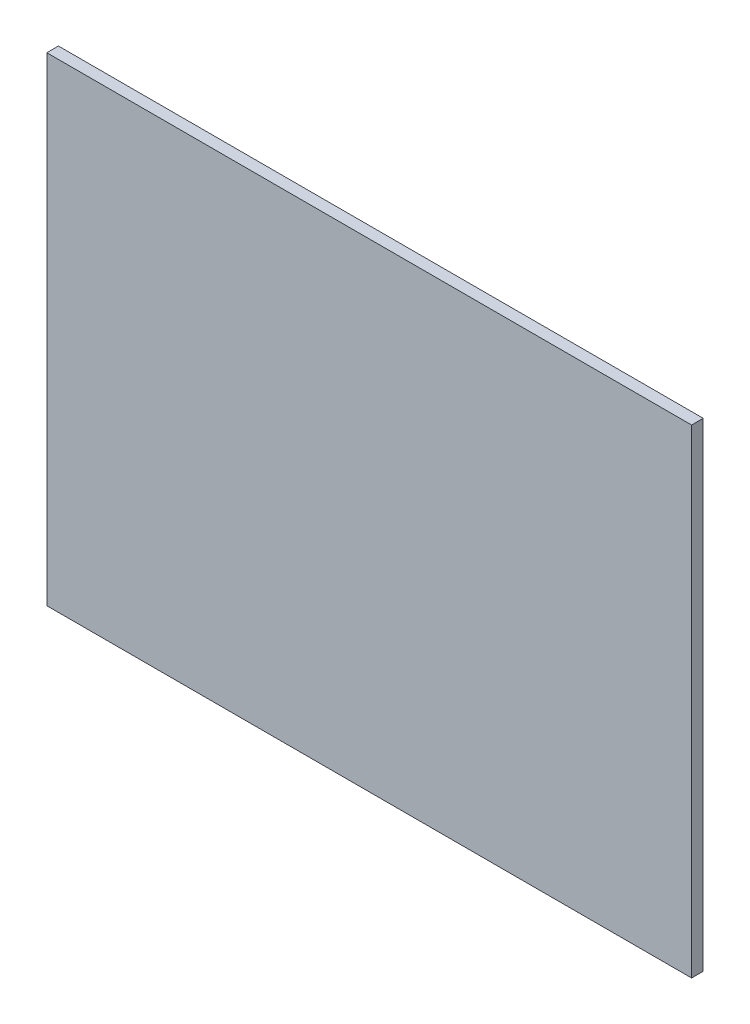
from build123d import *

# Parameters (mm, degrees)
SKETCH1_W           = 660.481708072
SKETCH1_H           = 490.53796101
BOSS_EXTRUDE1_DEPTH = 11.90625


with BuildPart() as part:
    # Sketch1 → Boss-Extrude1 (new body)
    with BuildSketch(Plane.XY):
        with Locations((0, 257.175230505)):
            Rectangle(SKETCH1_W, SKETCH1_H)
    extrude(amount=-BOSS_EXTRUDE1_DEPTH)


solid = part.part
